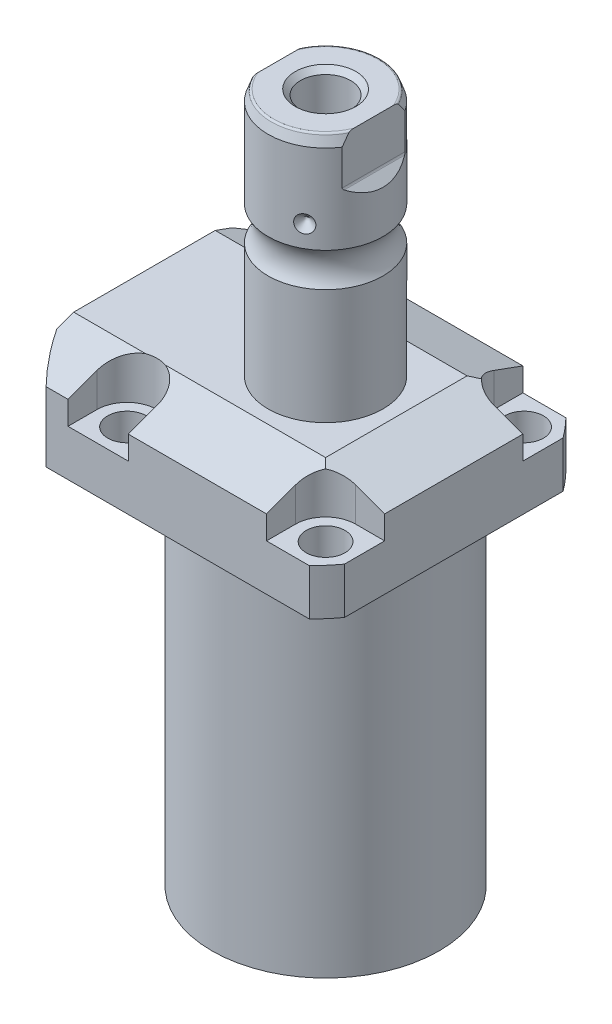
from build123d import *

# Parameters (mm, degrees)
SKETCH1_W                = 70.866
SKETCH1_H                = 85.496
EXTRUDE1_DEPTH           = 121.9708
SKETCH2_OUTSIDE_W        = 120.486
SKETCH2_OUTSIDE_H        = 105.856
SKETCH2_OUTSIDE_R        = 50.8
CUT_EXTRUDE1_DEPTH       = 122.9708
SKETCH3_W                = 45.1992
SKETCH3_H                = 96.9518
FILLET1_R                = 0.381
CUT_EXTRUDE2_DEPTH       = 12.243
CUT_EXTRUDE9_START       = -51.063
CUT_EXTRUDE9_DEPTH       = 87.496
CUT_EXTRUDE7_DEPTH       = 36.433
CUT_EXTRUDE7_DEPTH_BACK  = 36.433
SKETCH10_R               = 1.1811
SKETCH17_W               = 5.3594
SKETCH17_H               = 12.776
HOLE1_AT_2_COUNT         = 2
HOLE1_AT_2_PITCH         = 54.864
HOLE1_AT_3_COUNT         = 2
HOLE1_AT_3_PITCH         = 77.589412886
HOLE1_AT_4_COUNT         = 2
HOLE1_AT_4_PITCH         = 54.864
CHAMFER1_SIZE            = 0.635
FILLET2_R                = 0.635
CIRPATTERN1_COUNT        = 3
CUT_EXTRUDE10_DEPTH      = 36.433
CUT_EXTRUDE10_DEPTH_BACK = 36.433
CHAMFER2_SIZE            = 1.4351


with BuildPart() as part:
    # Sketch1 → Extrude1 (new body)
    with BuildSketch(Plane(origin=(0, 0, 0), x_dir=(0, 0, 1), z_dir=(0, -1, 0))):
        with Locations((0, 7.315)):
            Rectangle(SKETCH1_W, SKETCH1_H)
    extrude(amount=-EXTRUDE1_DEPTH)

    # Sketch2 outside → Cut-Extrude1 (cut, through all)
    with BuildSketch(Plane.XZ):
        with Locations((-7.315, 0)):
            Rectangle(SKETCH2_OUTSIDE_W, SKETCH2_OUTSIDE_H)
        with Locations((-5.4102, 0)):
            Circle(SKETCH2_OUTSIDE_R, mode=Mode.SUBTRACT)
    extrude(amount=-CUT_EXTRUDE1_DEPTH, mode=Mode.SUBTRACT)

    # Sketch3 → Cut-Revolve1 (revolve, cut)
    with BuildSketch(Plane(origin=(0, 0, 0), x_dir=(0, 0, -1), z_dir=(1, 0, 0))):
        with Locations((53.9941, 48.4759)):
            Rectangle(SKETCH3_W, SKETCH3_H)
    revolve(axis=Axis((0, -93.345, 0), (0, 1, 0)), mode=Mode.SUBTRACT)

    # Fillet1
    fillet1_edges = [part.edges().sort_by_distance(p)[0] for p in [
        (0, 96.9518, 31.3945),
    ]]
    fillet(fillet1_edges, radius=FILLET1_R)

    # Sketch4 → Cut-Extrude2 (cut)
    with BuildSketch(Plane(origin=(0, 121.9708, 0), x_dir=(-1, 0, 0), z_dir=(0, 1, 0))):
        with BuildLine():
            Line((-19.1008, -35.433), (-19.1008, -27.432))
            ThreePointArc((-19.1008, -27.432), (-21.540951985, -21.540951985), (-27.432, -19.1008))
            Line((-27.432, -19.1008), (-35.433, -19.1008))
            Line((-35.433, -19.1008), (-35.433, -35.433))
            Line((-35.433, -35.433), (-19.1008, -35.433))
        make_face()
        with BuildLine():
            Line((35.7632, -35.433), (19.1008, -35.433))
            Line((19.1008, -35.433), (19.1008, -27.432))
            ThreePointArc((19.1008, -27.432), (27.432, -19.1008), (35.7632, -27.432))
            Line((35.7632, -27.432), (35.7632, -35.433))
        make_face()
        with BuildLine():
            Line((19.1008, 35.433), (19.1008, 27.432))
            ThreePointArc((19.1008, 27.432), (27.432, 19.1008), (35.7632, 27.432))
            Line((35.7632, 27.432), (35.7632, 35.433))
            Line((35.7632, 35.433), (19.1008, 35.433))
        make_face()
        with BuildLine():
            Line((-27.432, 19.1008), (-35.433, 19.1008))
            Line((-35.433, 19.1008), (-35.433, 35.433))
            Line((-35.433, 35.433), (-19.1008, 35.433))
            Line((-19.1008, 35.433), (-19.1008, 27.432))
            ThreePointArc((-19.1008, 27.432), (-21.540951985, 21.540951985), (-27.432, 19.1008))
        make_face()
    extrude(amount=-CUT_EXTRUDE2_DEPTH, mode=Mode.SUBTRACT)

    # Sketch5 → Cut-Extrude9 (cut)
    with BuildSketch(Plane(origin=(0, 0, 0), x_dir=(0, 0, -1), z_dir=(1, 0, 0)).offset(CUT_EXTRUDE9_START)):
        Polygon((-19.558, 121.9708), (-35.433, 116.192772531), (-35.433, 121.9708), align=None)
    cut_extrude9 = extrude(amount=CUT_EXTRUDE9_DEPTH, mode=Mode.SUBTRACT)

    # Mirror1: Cut-Extrude9 across plane
    add(cut_extrude9.mirror(Plane.XY), mode=Mode.SUBTRACT)

    # Sketch9 → Cut-Extrude7 (cut, two sides)
    with BuildSketch(Plane.XY) as cut_extrude7_sk:
        Polygon((19.558, 121.9708), (35.433, 116.192772531), (35.433, 121.9708), align=None)
    extrude(amount=CUT_EXTRUDE7_DEPTH, mode=Mode.SUBTRACT)
    extrude(cut_extrude7_sk.sketch, amount=-CUT_EXTRUDE7_DEPTH_BACK, mode=Mode.SUBTRACT)

    # Sketch20 → Cut-Revolve4 (revolve, cut)
    with BuildSketch(Plane(origin=(-35.0774, 88.9, -18.1102), x_dir=(0, 1, 0), z_dir=(1, 0, 0)), mode=Mode.PRIVATE) as cut_revolve4_sk:
        Polygon((8.0518, 38.3413), (9.4996, 38.3413), (9.4996, 35.8902), (10.5156, 35.8902), (10.5156, 33.8836), (21.4884, 33.8836), (21.4884, 32.639), (8.0518, 32.639), align=None)
    cut_revolve4 = revolve(cut_revolve4_sk.sketch.rotate(Axis((-35.0774, 81.620304954, 14.5288), (0, 1, 0)), 180), axis=Axis((-35.0774, 81.620304954, 14.5288), (0, 1, 0)), mode=Mode.SUBTRACT)  # turned: the seam where the file's is

    # Mirror10: Cut-Revolve4 across plane
    add(cut_revolve4.mirror(Plane.XY), mode=Mode.SUBTRACT)

    # Sketch15 → Revolve3 (revolve)
    with BuildSketch(Plane(origin=(0, 0, 0), x_dir=(0, 0, -1), z_dir=(1, 0, 0)), mode=Mode.PRIVATE) as revolve3_sk:
        with BuildLine():
            Line((0, 121.9708), (15.875, 121.9708))
            Line((15.875, 121.9708), (15.875, 153.81390643))
            ThreePointArc((15.875, 153.81390643), (14.3256, 158.521), (15.875, 163.22809357))
            Line((15.875, 163.22809357), (15.875, 187.70599416))
            Line((15.875, 187.70599416), (14.81184082, 190.627))
            Line((14.81184082, 190.627), (0, 190.627))
            Line((0, 190.627), (0, 121.9708))
        make_face()
    revolve(revolve3_sk.sketch.rotate(Axis((0, 250.290824608, 0), (0, -1, 0)), 180), axis=Axis((0, 250.290824608, 0), (0, -1, 0)))  # turned: the seam where the file's is

    # Sketch17 → Hole1 (revolve, cut)
    with BuildSketch(Plane(origin=(27.432, 109.7278, -27.432), x_dir=(0, 0, 1), z_dir=(1, 0, 0))):
        with Locations((2.6797, 6.388)):
            Rectangle(SKETCH17_W, SKETCH17_H)
    hole1 = revolve(axis=Axis((27.432, -0.2722, -27.432), (0, 1, 0)), mode=Mode.SUBTRACT)

    # Hole1 at 2: Hole1 ×2
    with Locations(*[(0, 0, i * HOLE1_AT_2_PITCH) for i in range(1, HOLE1_AT_2_COUNT)]):
        add(hole1, mode=Mode.SUBTRACT)

    # Hole1 at 3: Hole1 ×2
    with Locations(*[Vector(-0.707106781, 0, 0.707106781) * (i * HOLE1_AT_3_PITCH) for i in range(1, HOLE1_AT_3_COUNT)]):
        add(hole1, mode=Mode.SUBTRACT)

    # Hole1 at 4: Hole1 ×2
    with Locations(*[(-i * HOLE1_AT_4_PITCH, 0, 0) for i in range(1, HOLE1_AT_4_COUNT)]):
        add(hole1, mode=Mode.SUBTRACT)

    # Chamfer1
    chamfer1_edges = [part.edges().sort_by_distance(p)[0] for p in [
        (-35.0774, 99.4156, 15.7734),
        (-35.0774, 99.4156, -15.7734),
    ]]
    chamfer(chamfer1_edges, length=CHAMFER1_SIZE)

    # Sketch21 → Cut-Revolve5 (revolve, cut)
    with BuildSketch(Plane.XZ.offset(-109.4486)):
        Polygon((-50.063, -1.9304), (-49.809, -1.9304), (-49.809, -6.7564), (-47.2563, -7.440393904), (-46.695693904, -8.001), (-30.759, -8.001), (-30.759, -12.9794), (-50.063, -12.9794), align=None)
    cut_revolve5 = revolve(axis=Axis((-57.549532301, 109.4486, -12.9794), (1, 0, 0)), mode=Mode.SUBTRACT)

    # Mirror13: Cut-Revolve5 across plane
    add(cut_revolve5.mirror(Plane.XY), mode=Mode.SUBTRACT)

    # Fillet2
    fillet2_edges = [part.edges().sort_by_distance(p)[0] for p in [
        (0, 190.627, -14.81184082),
    ]]
    fillet(fillet2_edges, radius=FILLET2_R)

    # Sketch26 → Cut-Revolve7 (revolve, cut)
    with BuildSketch(Plane.XY, mode=Mode.PRIVATE) as cut_revolve7_sk:
        Polygon((-15.875, 171.602), (-13.462, 169.189), (-15.875, 169.189), align=None)
    cut_revolve7 = revolve(cut_revolve7_sk.sketch.rotate(Axis((-39.772000707, 169.189, 0), (1, 0, 0)), 90), axis=Axis((-39.772000707, 169.189, 0), (1, 0, 0)), mode=Mode.SUBTRACT)  # turned: the seam where the file's is

    # CirPattern1: Cut-Revolve7 ×3 about axis
    cirpattern1_axis = Axis((0, 250.290824608, 0), (0, 1, 0))
    for i in range(1, CIRPATTERN1_COUNT):
        add(cut_revolve7.rotate(cirpattern1_axis, i * 360 / CIRPATTERN1_COUNT), mode=Mode.SUBTRACT)

    # Sketch27 → Hole2 (revolve, cut)
    with BuildSketch(Plane(origin=(0, 190.627, 0), x_dir=(0, 0, 1), z_dir=(1, 0, 0))):
        Polygon((0, 0), (0, 28.812118634), (6.9469, 24.638), (6.9469, 0), align=None)
    revolve(axis=Axis((0, 194.871199587, 0), (0, -1, 0)), mode=Mode.SUBTRACT)

    # Sketch29 → Cut-Extrude10 (cut, two sides)
    with BuildSketch(Plane.XY) as cut_extrude10_sk:
        with BuildLine():
            Line((13.284, 190.627), (13.284, 177.927))
            ThreePointArc((13.284, 177.927), (13.342003912, 177.635394643), (13.507185078, 177.388183558))
            Line((13.507185078, 177.388183558), (16.332, 174.563368636))
            Line((16.332, 174.563368636), (16.332, 190.627))
            Line((16.332, 190.627), (13.284, 190.627))
        make_face()
        with BuildLine():
            Line((-16.332, 190.627), (-13.284, 190.627))
            Line((-13.284, 190.627), (-13.284, 177.927))
            ThreePointArc((-13.284, 177.927), (-13.342003912, 177.635394643), (-13.507185078, 177.388183558))
            Line((-13.507185078, 177.388183558), (-16.332, 174.563368636))
            Line((-16.332, 174.563368636), (-16.332, 190.627))
        make_face()
    extrude(amount=CUT_EXTRUDE10_DEPTH, mode=Mode.SUBTRACT)
    extrude(cut_extrude10_sk.sketch, amount=-CUT_EXTRUDE10_DEPTH_BACK, mode=Mode.SUBTRACT)

    # Chamfer2
    chamfer2_edges = [part.edges().sort_by_distance(p)[0] for p in [
        (0, 190.627, -6.9469),
    ]]
    chamfer(chamfer2_edges, length=CHAMFER2_SIZE)


with BuildPart() as body_2:
    # Sketch10 → Revolve4 (revolve)
    with BuildSketch(Plane(origin=(-35.0774, 88.9, -18.1102), x_dir=(0, 1, 0), z_dir=(1, 0, 0))):
        with Locations((8.3185, 8.1026)):
            Circle(SKETCH10_R)
    revolve(axis=Axis((-35.0774, 87.86749, -14.5288), (0, 1, 0)))


with BuildPart() as body_3:
    # Mirror12: mirrored copy
    add(body_2.part.mirror(Plane.XY))


solid = Compound([part.part, body_2.part, body_3.part])
